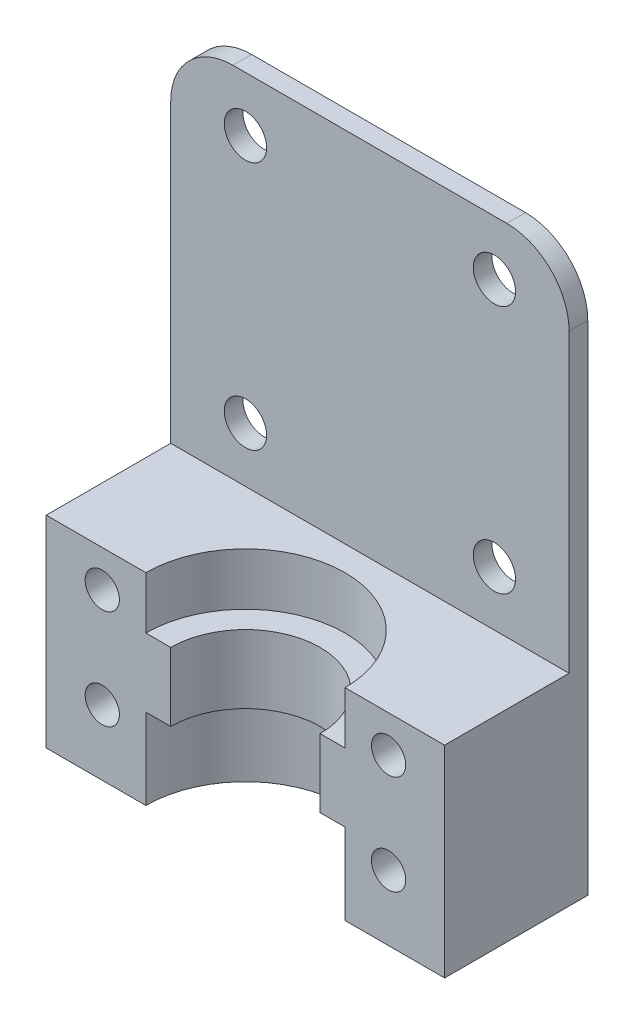
from build123d import *

# Parameters (mm, degrees)
SKETCH1_W                 = 1.5
SKETCH1_H                 = 45
BOSS_EXTRUDE1_DEPTH       = 16
SKETCH2_W                 = 32
SKETCH2_H                 = 10
BOSS_EXTRUDE2_DEPTH       = 16.2
M3X0_5_TAPPED_HOLE1_D     = 2.75
M3X0_5_TAPPED_HOLE1_DEPTH = 12
M3X0_5_TAPPED_HOLE1_TIP   = 0.826183351
BOSS_EXTRUDE3_DEPTH       = 5
FILLET1_R                 = 0.5
M3_CLEARANCE_HOLE1_D      = 3.4
FILLET2_R                 = 5


with BuildPart() as part:
    # Sketch1 → Boss-Extrude1 (new body, symmetric)
    with BuildSketch(Plane(origin=(0, 0, 0), x_dir=(0, 0, -1), z_dir=(1, 0, 0))):
        with Locations((0.75, 22.5)):
            Rectangle(SKETCH1_W, SKETCH1_H)
    extrude(amount=BOSS_EXTRUDE1_DEPTH, both=True)

    # Sketch2 → Boss-Extrude2 (add)
    with BuildSketch(Plane(origin=(0, 0, 0), x_dir=(1, 0, 0), z_dir=(0, 1, 0))):
        with Locations((0, -5)):
            Rectangle(SKETCH2_W, SKETCH2_H)
    extrude(amount=BOSS_EXTRUDE2_DEPTH)

    # Sketch9 → Cut-Revolve1 (revolve, cut)
    with BuildSketch(Plane(origin=(0, 0, 0), x_dir=(0, 0, -1), z_dir=(1, 0, 0))):
        Polygon((-10, 16.2), (-2, 16.2), (-2, 12), (-4, 12), (-4, 6.5), (-2, 6.5), (-2, 0), (-10, 0), align=None)
    revolve(axis=Axis((0, 0, 10), (0, 1, 0)), mode=Mode.SUBTRACT)

    # M3x0.5 Tapped Hole1
    with Locations(Plane.XY.offset(10)):
        with Locations((-11.5, 13.25), (11.5, 13.25), (-11.5, 5.25), (11.5, 5.25)):
            Hole(M3X0_5_TAPPED_HOLE1_D / 2, depth=M3X0_5_TAPPED_HOLE1_DEPTH)
            with Locations((0, 0, -(M3X0_5_TAPPED_HOLE1_DEPTH + M3X0_5_TAPPED_HOLE1_TIP / 2))):  # 118° drill point
                Cone(0, M3X0_5_TAPPED_HOLE1_D / 2, M3X0_5_TAPPED_HOLE1_TIP, mode=Mode.SUBTRACT)

    # Sketch13 → Boss-Extrude3 (add)
    with BuildSketch(Plane.XZ):
        Polygon((-7.375, -1.5), (-9.375, -3.5), (9.375, -3.5), (7.375, -1.5), align=None)
    extrude(amount=-BOSS_EXTRUDE3_DEPTH)

    # Fillet1
    fillet1_edges = [part.edges().sort_by_distance(p)[0] for p in [
        (-7.375, 2.5, -1.5),
        (7.375, 2.5, -1.5),
        (9.375, 2.5, -3.5),
        (-9.375, 2.5, -3.5),
    ]]
    fillet(fillet1_edges, radius=FILLET1_R)

    # M3 Clearance Hole1 (through all)
    with Locations(Plane.XY):
        with Locations((-10, 20.6), (-10, 40.6), (10, 40.6), (10, 20.6)):
            Hole(M3_CLEARANCE_HOLE1_D / 2)

    # Fillet2
    fillet2_edges = [part.edges().sort_by_distance(p)[0] for p in [
        (16, 45, -0.75),
        (-16, 45, -0.75),
    ]]
    fillet(fillet2_edges, radius=FILLET2_R)


solid = part.part
